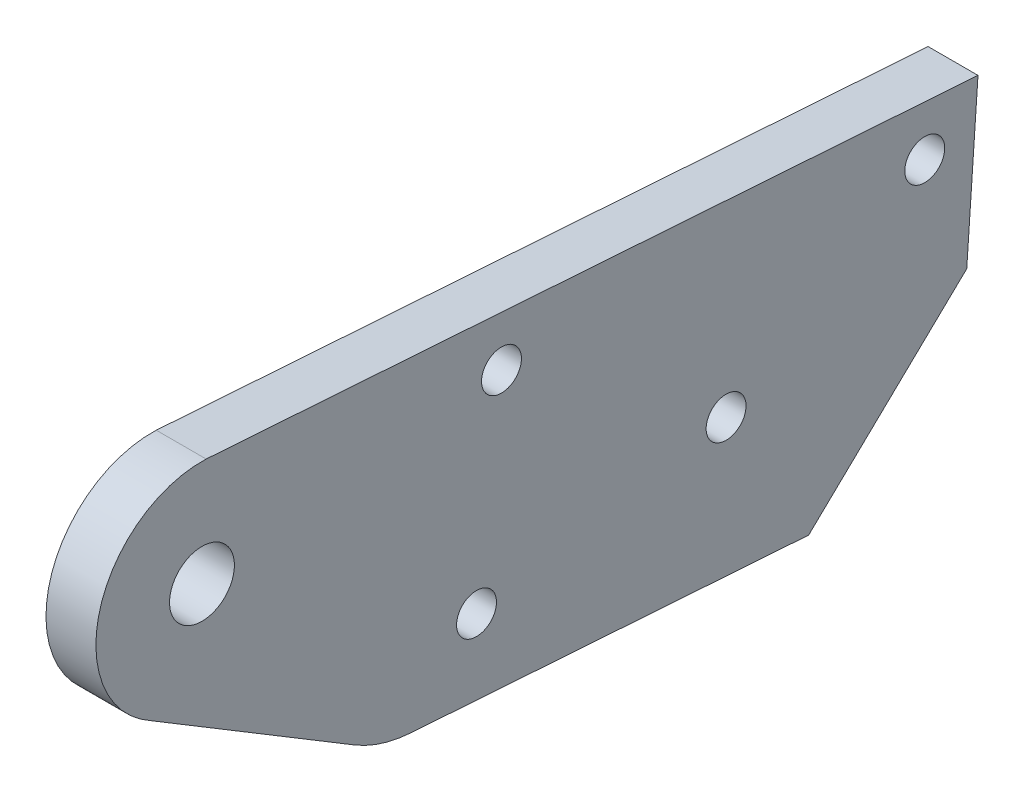
from build123d import *

# Parameters (mm, degrees)
SKETCH_1_R      = 1.6
SKETCH_1_R_2    = 2.6
EXTRUDE_1_DEPTH = 4


with BuildPart() as part:
    # 草图1 → 凸台-拉伸1 (new body)
    with BuildSketch(Plane(origin=(0, 0, 0), x_dir=(0, 0, -1), z_dir=(1, 0, 0))):
        with BuildLine():
            Line((15.96147647, -1.109625561), (28.630049258, 11.041044095))
            Line((28.630049258, 11.041044095), (29.531620026, 24.009743728))
            Line((29.531620026, 24.009743728), (-32.319101296, 28.309542775))
            ThreePointArc((-32.319101296, 28.309542775), (-40.839313336, 22.108629409), (-36.779478782, 12.384274255))
            Line((-36.779478782, 12.384274255), (-20.433580884, 2.523050705))
            ThreePointArc((-20.433580884, 2.523050705), (-18.281565047, 1.550445439), (-15.96147647, 1.109625561))
            Line((-15.96147647, 1.109625561), (15.96147647, -1.109625561))
        make_face()
        with Locations((25.263844519, 20.296781)):
            Circle(SKETCH_1_R, mode=Mode.SUBTRACT)
        with Locations((-8.654292981, 22.654735317)):
            Circle(SKETCH_1_R, mode=Mode.SUBTRACT)
        with Locations((9.345707019, 10.376844831)):
            Circle(SKETCH_1_R, mode=Mode.SUBTRACT)
        with Locations((-10.654292981, 6.755156769)):
            Circle(SKETCH_1_R, mode=Mode.SUBTRACT)
        with Locations((-32.654292981, 19.816154374)):
            Circle(SKETCH_1_R_2, mode=Mode.SUBTRACT)
    extrude(amount=EXTRUDE_1_DEPTH)


solid = part.part
